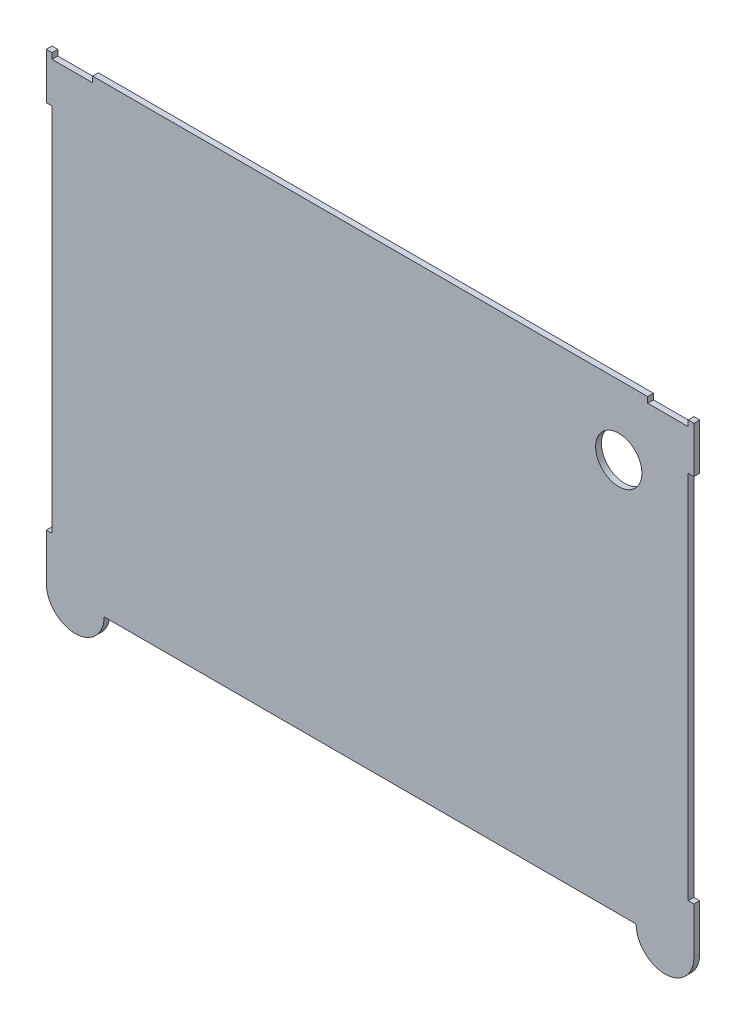
from build123d import *

# Parameters (mm, degrees)
BOSS_EXTRUDE1_DEPTH = 3.175
SKETCH2_R           = 12.7
CUT_EXTRUDE1_DEPTH  = 4.175


with BuildPart() as part:
    # Sketch1 → Boss-Extrude1 (new body)
    with BuildSketch(Plane.XY):
        with BuildLine():
            Line((0, 228.6), (0, 250.825))
            Line((0, 250.825), (0, 254))
            Line((0, 254), (3.175, 254))
            Line((3.175, 254), (3.175, 250.825))
            Line((3.175, 250.825), (25.4, 250.825))
            Line((25.4, 250.825), (25.4, 254))
            Line((25.4, 254), (330.2, 254))
            Line((330.2, 254), (330.2, 250.825))
            Line((330.2, 250.825), (352.425, 250.825))
            Line((352.425, 250.825), (352.425, 254))
            Line((352.425, 254), (355.6, 254))
            Line((355.6, 254), (355.6, 250.825))
            Line((355.6, 250.825), (355.6, 228.6))
            Line((355.6, 228.6), (352.425, 228.6))
            Line((352.425, 228.6), (352.425, 25.4))
            Line((352.425, 25.4), (355.6, 25.4))
            Line((355.6, 25.4), (355.6, 0))
            ThreePointArc((355.6, 0), (339.725, -15.875), (323.85, 0))
            Line((323.85, 0), (31.75, 0))
            ThreePointArc((31.75, 0), (15.875, -15.875), (0, 0))
            Line((0, 0), (0, 25.4))
            Line((0, 25.4), (3.175, 25.4))
            Line((3.175, 25.4), (3.175, 228.6))
            Line((3.175, 228.6), (0, 228.6))
        make_face()
    extrude(amount=BOSS_EXTRUDE1_DEPTH)

    # Sketch2 → Cut-Extrude1 (cut, through all)
    with BuildSketch(Plane.XY.offset(3.175)):
        with Locations((314.325, 215.9)):
            Circle(SKETCH2_R)
    extrude(amount=-CUT_EXTRUDE1_DEPTH, mode=Mode.SUBTRACT)


solid = part.part
